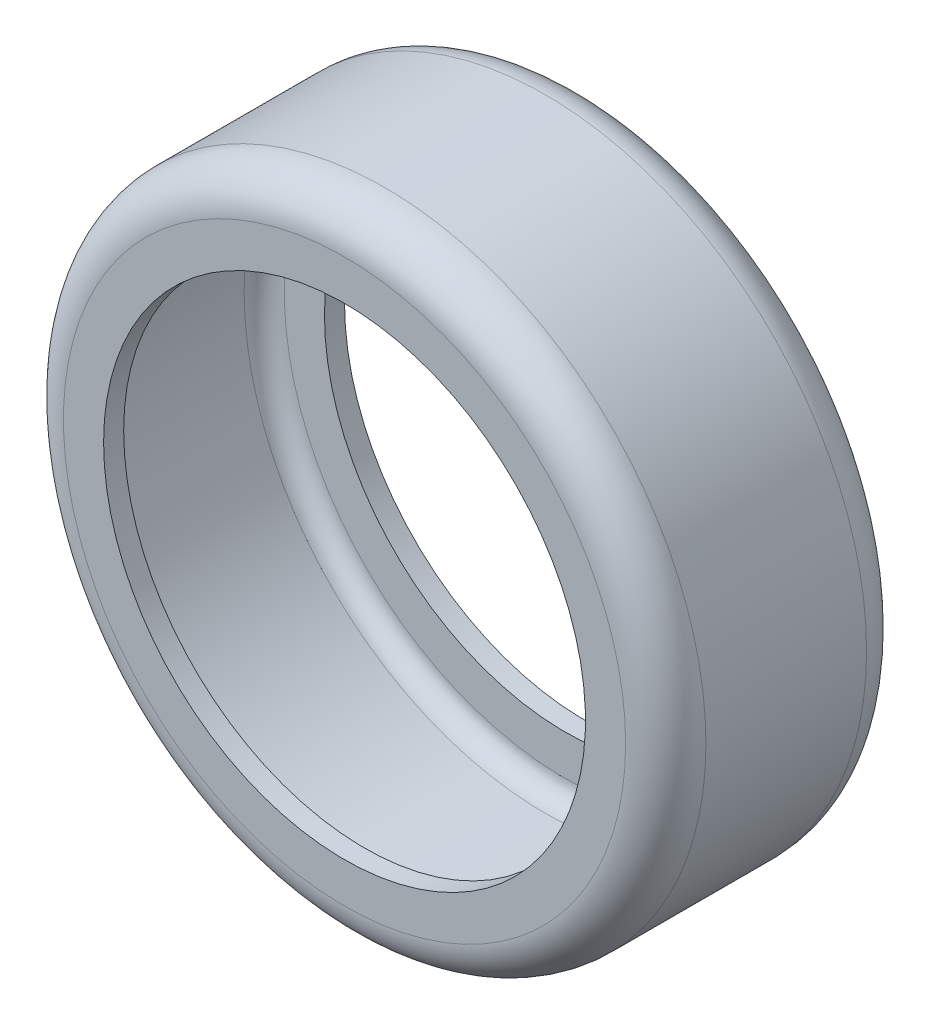
from build123d import *

# Parameters (mm, degrees)
SKETCH2_R           = 101.6
SKETCH2_R_2         = 76.2
BOSS_EXTRUDE1_DEPTH = 38.1
FILLET2_R           = 12.7
SHELL1_T            = -6.35


with BuildPart() as part:
    # Sketch2 → Boss-Extrude1 (new, symmetric)
    with BuildSketch(Plane.XY):
        with Locations(Location((0, 0, 0), (0, 0, 180))):
            Circle(SKETCH2_R)
        with Locations(Location((0, 0, 0), (0, 0, 180))):
            Circle(SKETCH2_R_2, mode=Mode.SUBTRACT)
    extrude(amount=BOSS_EXTRUDE1_DEPTH, both=True)

    # Fillet2
    fillet2_edges = [part.edges().sort_by_distance(p)[0] for p in [
        (101.6, 0, -38.1),
        (101.6, 0, 38.1),
    ]]
    fillet(fillet2_edges, radius=FILLET2_R)

    # Shell1
    shell1_openings = [part.faces().sort_by_distance(p)[0] for p in [
        (76.2, 0, 0),
    ]]
    offset(amount=SHELL1_T, openings=shell1_openings, kind=Kind.INTERSECTION)


solid = part.part
